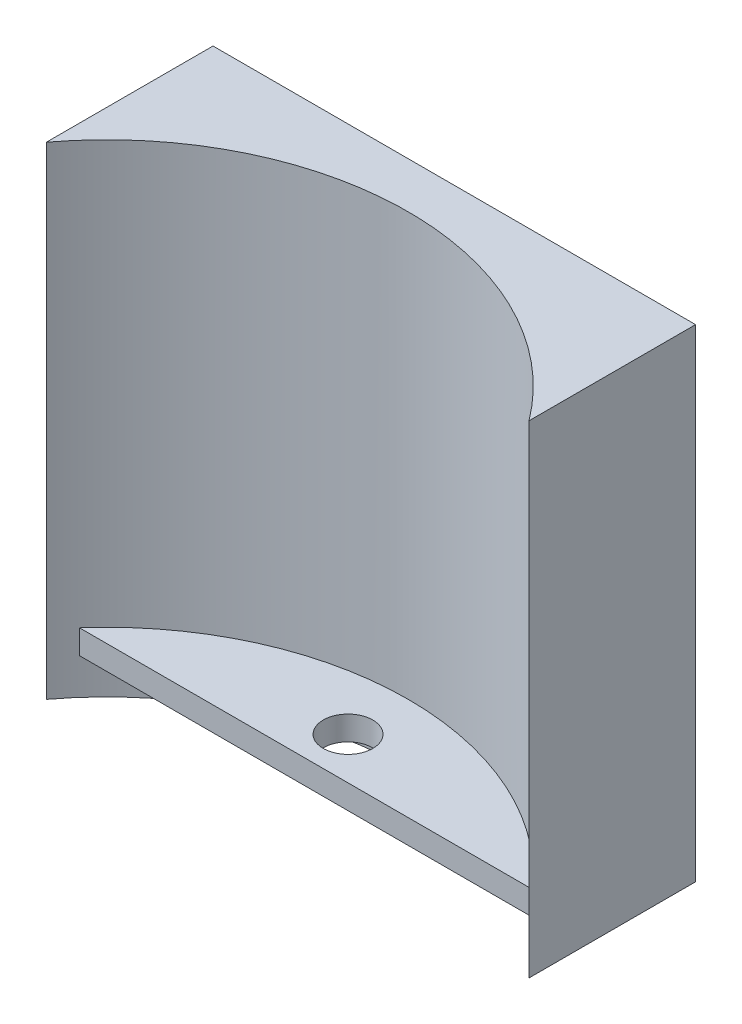
from build123d import *

# Parameters (mm, degrees)
BOSS_EXTRUDE1_DEPTH = 40
SKETCH7_W           = 40
SKETCH7_H           = 10
BOSS_EXTRUDE2_DEPTH = 2
SKETCH8_R           = 2.05
CUT_EXTRUDE1_DEPTH  = 38


with BuildPart() as part:
    # Sketch6 → Boss-Extrude1 (new body)
    with BuildSketch(Plane(origin=(0, 0, 0), x_dir=(1, 0, 0), z_dir=(0, 1, 0))):
        with BuildLine():
            Line((20, 28.809017417), (-20, 28.809017417))
            Line((-20, 28.809017417), (-20, 15))
            ThreePointArc((-20, 15), (0, 25), (20, 15))
            Line((20, 15), (20, 28.809017417))
        make_face()
    extrude(amount=BOSS_EXTRUDE1_DEPTH)

    # Sketch7 → Boss-Extrude2 (add)
    with BuildSketch(Plane(origin=(0, 5, 0), x_dir=(-1, 0, 0), z_dir=(0, -1, 0))):
        with Locations((0, 21.508861193)):
            Rectangle(SKETCH7_W, SKETCH7_H)
    extrude(amount=BOSS_EXTRUDE2_DEPTH)

    # Sketch8 → Cut-Extrude1 (cut, through all)
    with BuildSketch(Plane.XZ.offset(-3)):
        with Locations((0, -20)):
            Circle(SKETCH8_R)
    extrude(amount=-CUT_EXTRUDE1_DEPTH, mode=Mode.SUBTRACT)


solid = part.part
